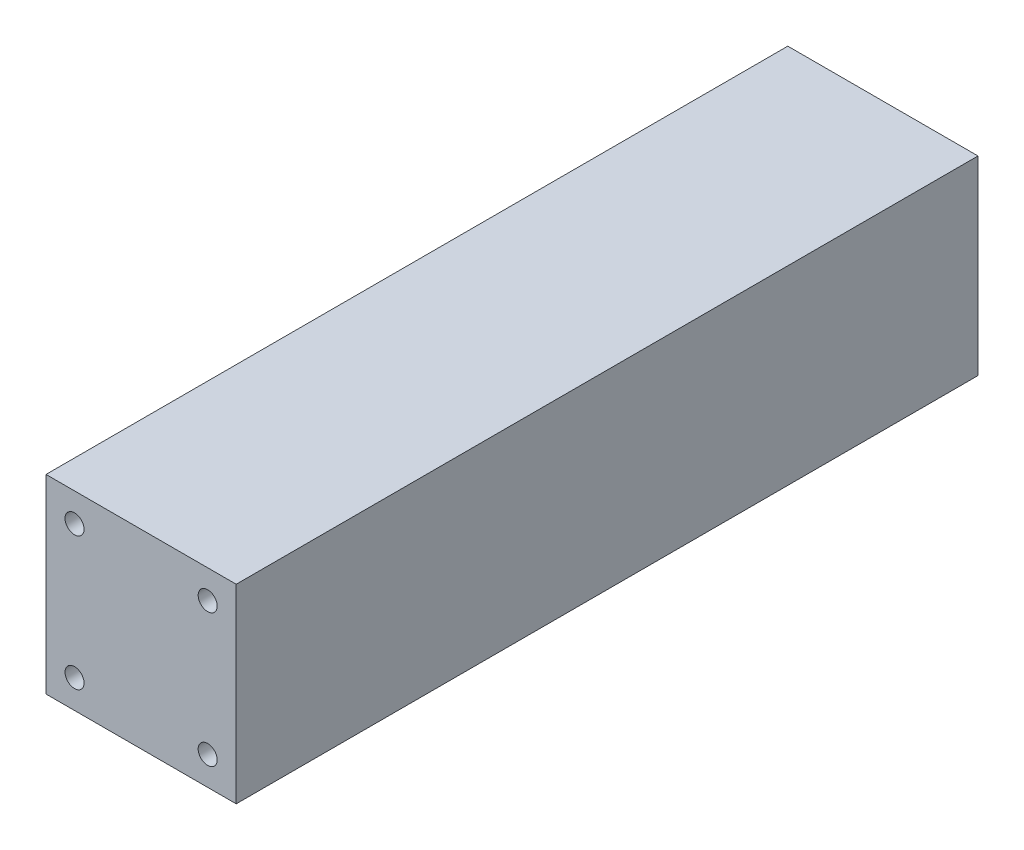
from build123d import *

# Parameters (mm, degrees)
SKETCH1_W                         = 127
SKETCH1_H                         = 127
BOSS_EXTRUDE1_DEPTH               = 495.3
F_1_2_13_TAPPED_HOLE1_D           = 10.71626
F_1_2_13_TAPPED_HOLE1_DEPTH       = 31.2674
F_1_2_13_TAPPED_HOLE1_CBORE_D     = 12.7
F_1_2_13_TAPPED_HOLE1_CBORE_DEPTH = 25.4
F_1_2_13_TAPPED_HOLE1_TIP         = 3.219489309
F_1_2_13_TAPPED_HOLE2_D           = 10.71626
F_1_2_13_TAPPED_HOLE2_DEPTH       = 31.2674
F_1_2_13_TAPPED_HOLE2_CBORE_D     = 12.7
F_1_2_13_TAPPED_HOLE2_CBORE_DEPTH = 25.4
F_1_2_13_TAPPED_HOLE2_TIP         = 3.219489309


with BuildPart() as part:
    # Sketch1 → Boss-Extrude1 (new body)
    with BuildSketch(Plane.XY):
        Rectangle(SKETCH1_W, SKETCH1_H)
    extrude(amount=BOSS_EXTRUDE1_DEPTH)

    # 1/2-13 Tapped Hole1
    with Locations(Plane.XY.offset(495.3)):
        with Locations((44.45, 44.45), (44.45, -44.45), (-44.45, -44.45), (-44.45, 44.45)):
            CounterBoreHole(F_1_2_13_TAPPED_HOLE1_D / 2, F_1_2_13_TAPPED_HOLE1_CBORE_D / 2, F_1_2_13_TAPPED_HOLE1_CBORE_DEPTH, depth=F_1_2_13_TAPPED_HOLE1_DEPTH)
            with Locations((0, 0, -(F_1_2_13_TAPPED_HOLE1_DEPTH + F_1_2_13_TAPPED_HOLE1_TIP / 2))):  # 118° drill point
                Cone(0, F_1_2_13_TAPPED_HOLE1_D / 2, F_1_2_13_TAPPED_HOLE1_TIP, mode=Mode.SUBTRACT)

    # 1/2-13 Tapped Hole2
    with Locations(Plane(origin=(0, 0, 0), x_dir=(-1, 0, 0), z_dir=(0, 0, -1))):
        with Locations((-44.45, 44.45), (44.45, 44.45), (-44.45, -44.45), (44.45, -44.45)):
            CounterBoreHole(F_1_2_13_TAPPED_HOLE2_D / 2, F_1_2_13_TAPPED_HOLE2_CBORE_D / 2, F_1_2_13_TAPPED_HOLE2_CBORE_DEPTH, depth=F_1_2_13_TAPPED_HOLE2_DEPTH)
            with Locations((0, 0, -(F_1_2_13_TAPPED_HOLE2_DEPTH + F_1_2_13_TAPPED_HOLE2_TIP / 2))):  # 118° drill point
                Cone(0, F_1_2_13_TAPPED_HOLE2_D / 2, F_1_2_13_TAPPED_HOLE2_TIP, mode=Mode.SUBTRACT)


solid = part.part
